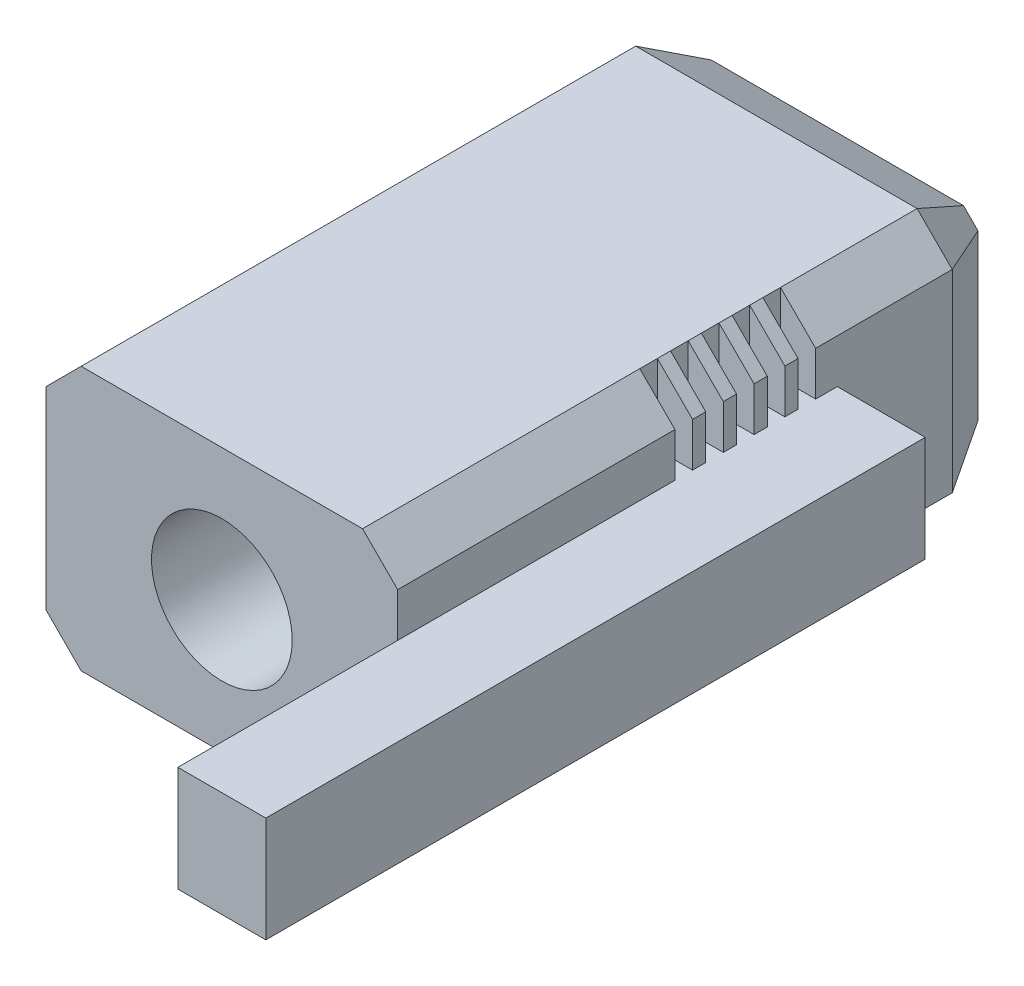
from build123d import *

# Parameters (mm, degrees)
SKETCH1_W           = 20
SKETCH1_H           = 15
BOSS_EXTRUDE1_DEPTH = 35
SKETCH2_R           = 4
CUT_EXTRUDE1_DEPTH  = 36
CHAMFER1_SIZE       = 2
CHAMFER2_SIZE       = 2
CHAMFER2_SIZE2      = 3.464101615
SKETCH4_W           = 2
SKETCH4_H           = 1
CUT_EXTRUDE2_DEPTH  = 16
SKETCH5_W           = 4
SKETCH5_H           = 8
SKETCH5_R           = 1.25
CUT_EXTRUDE3_DEPTH  = 1
SKETCH3_W           = 37.5
SKETCH3_H           = 6
BOSS_EXTRUDE2_DEPTH = 5
SKETCH6_W           = 8
SKETCH6_H           = 6
BOSS_EXTRUDE3_DEPTH = 2


with BuildPart() as part:
    # Sketch1 → Boss-Extrude1 (new body)
    with BuildSketch(Plane.XY):
        Rectangle(SKETCH1_W, SKETCH1_H)
    extrude(amount=BOSS_EXTRUDE1_DEPTH)

    # Sketch2 → Cut-Extrude1 (cut, through all)
    with BuildSketch(Plane.XY.offset(35)):
        Circle(SKETCH2_R)
    extrude(amount=-CUT_EXTRUDE1_DEPTH, mode=Mode.SUBTRACT)

    # Chamfer1
    chamfer1_edges = [part.edges().sort_by_distance(p)[0] for p in [
        (10, 7.5, 17.5),
        (10, -7.5, 17.5),
        (-10, -7.5, 17.5),
        (-10, 7.5, 17.5),
    ]]
    chamfer(chamfer1_edges, length=CHAMFER1_SIZE)

    # Chamfer2
    chamfer2_edges = [part.edges().sort_by_distance(p)[0] for p in [
        (-10, 0, 0),
        (0, 7.5, 0),
        (10, 0, 0),
        (0, -7.5, 0),
        (9, 6.5, 0),
        (9, -6.5, 0),
        (-9, -6.5, 0),
        (-9, 6.5, 0),
    ]]
    chamfer2_side = [part.faces().sort_by_distance(p)[0] for p in [
        (-9.75, 0, 0),
    ]]
    chamfer(chamfer2_edges, length=CHAMFER2_SIZE, length2=CHAMFER2_SIZE2, reference=chamfer2_side[0])

    # Sketch4 → Cut-Extrude2 (cut, through all)
    with BuildSketch(Plane.XZ.offset(7.5)):
        with Locations((-9, 11.732050808)):
            Rectangle(SKETCH4_W, SKETCH4_H)
        with Locations((-9, 13.482050808)):
            Rectangle(SKETCH4_W, SKETCH4_H)
        with Locations((-9, 15.232050808)):
            Rectangle(SKETCH4_W, SKETCH4_H)
        with Locations((-9, 16.982050808)):
            Rectangle(SKETCH4_W, SKETCH4_H)
        with Locations((-9, 18.732050808)):
            Rectangle(SKETCH4_W, SKETCH4_H)
        with Locations((9, 18.732050808)):
            Rectangle(SKETCH4_W, SKETCH4_H)
        with Locations((9, 16.982050808)):
            Rectangle(SKETCH4_W, SKETCH4_H)
        with Locations((9, 15.232050808)):
            Rectangle(SKETCH4_W, SKETCH4_H)
        with Locations((9, 13.482050808)):
            Rectangle(SKETCH4_W, SKETCH4_H)
        with Locations((9, 11.732050808)):
            Rectangle(SKETCH4_W, SKETCH4_H)
    extrude(amount=-CUT_EXTRUDE2_DEPTH, mode=Mode.SUBTRACT)

    # Sketch5 → Cut-Extrude3 (cut)
    with BuildSketch(Plane.XZ.offset(7.5)):
        with Locations((0, 10)):
            Rectangle(SKETCH5_W, SKETCH5_H)
        with Locations((0, 9)):
            Circle(SKETCH5_R, mode=Mode.SUBTRACT)
    extrude(amount=-CUT_EXTRUDE3_DEPTH, mode=Mode.SUBTRACT)

    # Sketch3 → Boss-Extrude2 (add)
    with BuildSketch(Plane(origin=(10, 0, 0), x_dir=(0, 0, -1), z_dir=(1, 0, 0))):
        with Locations((-28.75, 0)):
            Rectangle(SKETCH3_W, SKETCH3_H)
    extrude(amount=BOSS_EXTRUDE2_DEPTH)

    # Sketch6 → Boss-Extrude3 (add)
    with BuildSketch(Plane.ZY.offset(-10)):
        with Locations((15.232050808, 0)):
            Rectangle(SKETCH6_W, SKETCH6_H)
    extrude(amount=BOSS_EXTRUDE3_DEPTH)


solid = part.part
